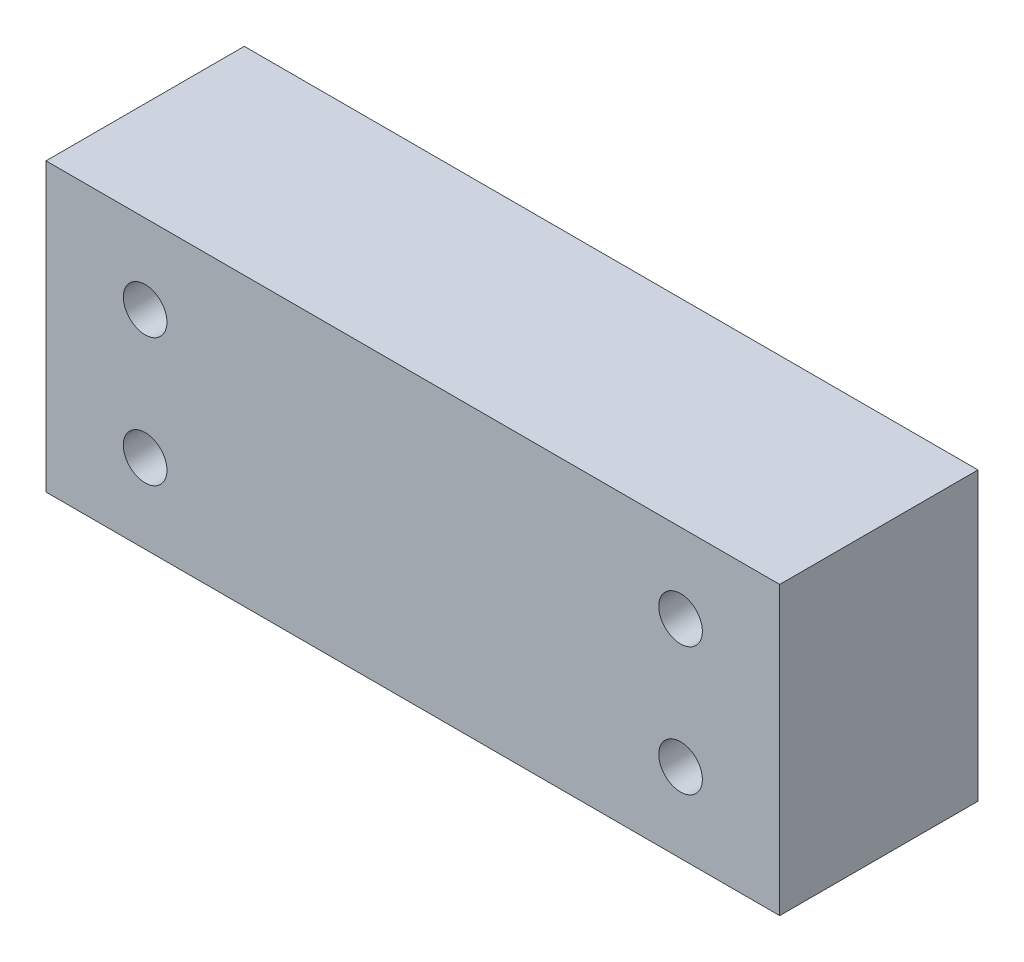
from build123d import *

# Parameters (mm, degrees)
SKETCH1_W           = 55.5
SKETCH1_H           = 21.7
SKETCH1_R           = 1.65
BOSS_EXTRUDE1_DEPTH = 15


with BuildPart() as part:
    # Sketch1 → Boss-Extrude1 (new body)
    with BuildSketch(Plane.XY):
        Rectangle(SKETCH1_W, SKETCH1_H)
        with Locations((20.25, 4.85)):
            Circle(SKETCH1_R, mode=Mode.SUBTRACT)
        with Locations((-20.25, 4.85)):
            Circle(SKETCH1_R, mode=Mode.SUBTRACT)
        with Locations((20.25, -4.85)):
            Circle(SKETCH1_R, mode=Mode.SUBTRACT)
        with Locations((-20.25, -4.85)):
            Circle(SKETCH1_R, mode=Mode.SUBTRACT)
    extrude(amount=BOSS_EXTRUDE1_DEPTH)


solid = part.part
